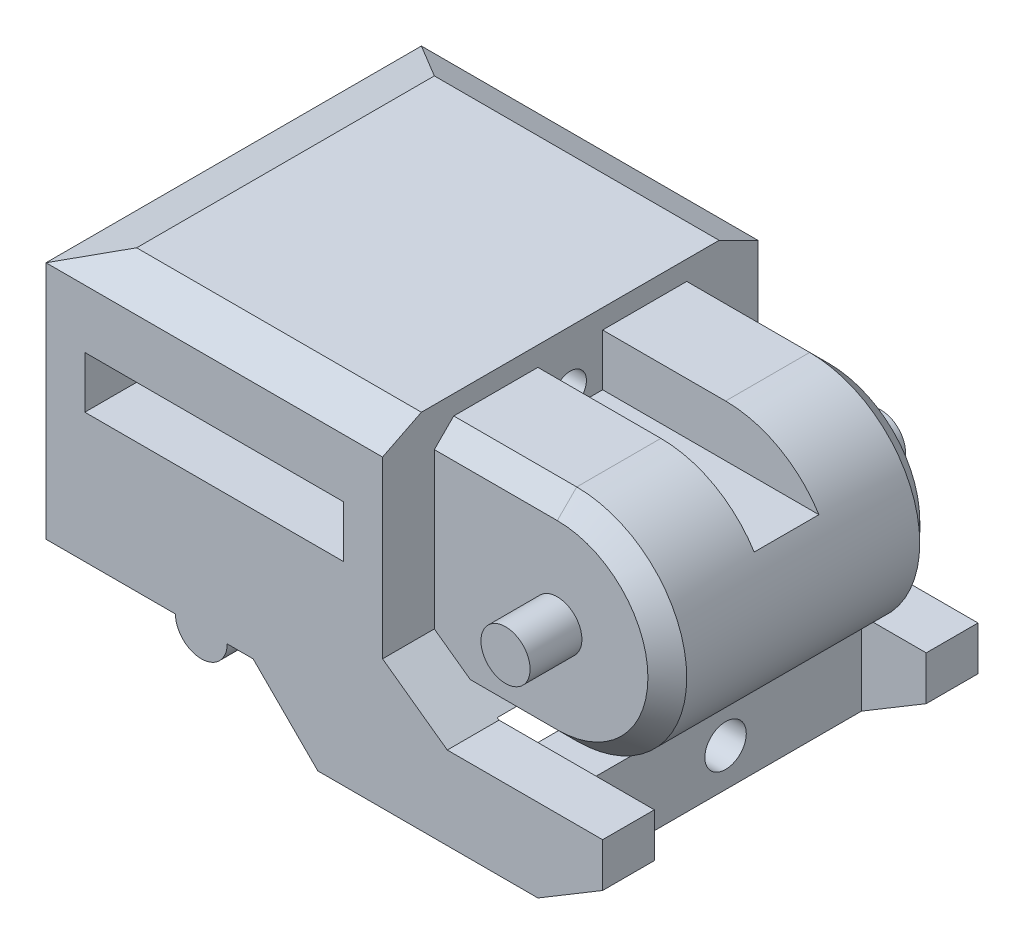
from build123d import *

# Parameters (mm, degrees)
SKETCH1_W                = 18
SKETCH1_H                = 21
BOSS_EXTRUDE1_DEPTH      = 20
CUT_EXTRUDE3_DEPTH       = 30
CUT_EXTRUDE4_DEPTH       = 27
SKETCH6_W                = 20
SKETCH6_H                = 17
CUT_EXTRUDE5_DEPTH       = 17
SKETCH9_W                = 17
SKETCH9_H                = 4
CUT_EXTRUDE7_DEPTH       = 4
SKETCH10_W               = 20
SKETCH10_H               = 4
CUT_EXTRUDE8_DEPTH       = 30
BOSS_EXTRUDE3_DEPTH      = 4
SKETCH13_W               = 18
SKETCH13_H               = 1.5
SKETCH13_W_2             = 20
CUT_EXTRUDE11_DEPTH      = 21
CUT_EXTRUDE12_DEPTH      = 26
SKETCH16_R               = 1.9
BOSS_EXTRUDE4_DEPTH      = 14.5
SKETCH22_R               = 1.25
CUT_EXTRUDE15_DEPTH      = 19
CUT_EXTRUDE15_DEPTH_BACK = 27
CHAMFER1_SIZE            = 1.5
SKETCH23_W               = 18
SKETCH23_H               = 5
CUT_EXTRUDE16_DEPTH      = 4
SKETCH24_R               = 2
BOSS_EXTRUDE7_DEPTH      = 29
BOSS_EXTRUDE8_REACH      = 31
SKETCH25_W               = 4.5
SKETCH25_H               = 5.9
SKETCH26_R               = 1.6
CUT_EXTRUDE17_DEPTH      = 10


with BuildPart() as part:
    # Sketch1 → Boss-Extrude1 (new body)
    with BuildSketch(Plane(origin=(0, 0, 0), x_dir=(1, 0, 0), z_dir=(0, 1, 0))):
        Polygon((17.5, 14.5), (-8.5, 14.5), (-8.5, -14.5), (17.5, -14.5), (17.5, -10.5), (17.5, 10.5), align=None)
        with Locations((26.5, 0)):
            Rectangle(SKETCH1_W, SKETCH1_H)
    extrude(amount=BOSS_EXTRUDE1_DEPTH)

    # Sketch3 → Cut-Extrude3 (cut, through all)
    with BuildSketch(Plane.XY.offset(14.5)):
        Polygon((-8.5, 20), (-8.5, 18.5), (-4.5, 20), align=None)
    extrude(amount=-CUT_EXTRUDE3_DEPTH, mode=Mode.SUBTRACT)

    # Sketch4 → Cut-Extrude4 (cut, through all)
    with BuildSketch(Plane(origin=(17.5, 0, 0), x_dir=(0, 0, -1), z_dir=(1, 0, 0))):
        Polygon((-14.5, 20), (-14.5, 18.5), (-11.5, 20), align=None)
        Polygon((14.5, 20), (11.5, 20), (14.5, 18.5), align=None)
    extrude(amount=-CUT_EXTRUDE4_DEPTH, mode=Mode.SUBTRACT)

    # Sketch6 → Cut-Extrude5 (cut)
    with BuildSketch(Plane.XZ):
        with Locations((4.5, 0)):
            Rectangle(SKETCH6_W, SKETCH6_H)
    extrude(amount=-CUT_EXTRUDE5_DEPTH, mode=Mode.SUBTRACT)

    # Sketch9 → Cut-Extrude7 (cut)
    with BuildSketch(Plane.ZY.offset(8.5)):
        with Locations((0, 15)):
            Rectangle(SKETCH9_W, SKETCH9_H)
    extrude(amount=-CUT_EXTRUDE7_DEPTH, mode=Mode.SUBTRACT)

    # Sketch10 → Cut-Extrude8 (cut, through all)
    with BuildSketch(Plane.XY.offset(14.5)):
        with Locations((4.5, 12)):
            Rectangle(SKETCH10_W, SKETCH10_H)
    extrude(amount=-CUT_EXTRUDE8_DEPTH, mode=Mode.SUBTRACT)

    # Sketch12 → Boss-Extrude3 (add)
    with BuildSketch(Plane.XY.offset(14.5)):
        Polygon((22.5, 1.4), (34.5, 1.4), (34.5, 0), (34.5, -2), (29.5, -5), (12.5, -5), (7.5, 0), (17.5, 0), (17.5, 5), align=None)
    boss_extrude3 = extrude(amount=-BOSS_EXTRUDE3_DEPTH)

    # Mirror1: Boss-Extrude3 across plane
    add(boss_extrude3.mirror(Plane.XY))

    # Sketch13 → Cut-Extrude11 (cut)
    with BuildSketch(Plane.XY.offset(10.5)):
        with Locations((26.5, 19.25)):
            Rectangle(SKETCH13_W, SKETCH13_H)
        with Locations((25.5, 0.75)):
            Rectangle(SKETCH13_W_2, SKETCH13_H)
    extrude(amount=-CUT_EXTRUDE11_DEPTH, mode=Mode.SUBTRACT)

    # Sketch14 → Cut-Extrude12 (cut, through all)
    with BuildSketch(Plane.XY.offset(10.5)):
        with BuildLine():
            ThreePointArc((35.5, 10), (33.01040764, 3.98959236), (27, 1.5))
            Line((27, 1.5), (35.5, 1.5))
            Line((35.5, 1.5), (35.5, 10))
        make_face()
        with BuildLine():
            Line((35.5, 18.5), (27, 18.5))
            ThreePointArc((27, 18.5), (33.01040764, 16.01040764), (35.5, 10))
            Line((35.5, 10), (35.5, 18.5))
        make_face()
    extrude(amount=-CUT_EXTRUDE12_DEPTH, mode=Mode.SUBTRACT)

    # Sketch16 → Boss-Extrude4 (add, symmetric)
    with BuildSketch(Plane.XY):
        with Locations((27, 10)):
            Circle(SKETCH16_R)
    extrude(amount=BOSS_EXTRUDE4_DEPTH, both=True)

    # Sketch22 → Cut-Extrude15 (cut, two sides)
    with BuildSketch(Plane(origin=(17.5, 0, 0), x_dir=(0, 0, -1), z_dir=(1, 0, 0))) as cut_extrude15_sk:
        with Locations((0, 15.75)):
            Circle(SKETCH22_R)
    extrude(amount=CUT_EXTRUDE15_DEPTH, mode=Mode.SUBTRACT)
    extrude(cut_extrude15_sk.sketch, amount=-CUT_EXTRUDE15_DEPTH_BACK, mode=Mode.SUBTRACT)

    # Chamfer1
    chamfer1_edges = [part.edges().sort_by_distance(p)[0] for p in [
        (22.25, 18.5, -10.5),
        (22.25, 18.5, 10.5),
        (24.680555556, 1.5, 10.5),
        (24.680555556, 1.5, -10.5),
        (35.5, 10, -10.5),
        (35.5, 10, 10.5),
    ]]
    chamfer(chamfer1_edges, length=CHAMFER1_SIZE)

    # Sketch23 → Cut-Extrude16 (cut)
    with BuildSketch(Plane(origin=(0, 18.5, 0), x_dir=(1, 0, 0), z_dir=(0, 1, 0))):
        with Locations((26.5, 0)):
            Rectangle(SKETCH23_W, SKETCH23_H)
    extrude(amount=-CUT_EXTRUDE16_DEPTH, mode=Mode.SUBTRACT)

    # Sketch24 → Boss-Extrude7 (add, through all)
    with BuildSketch(Plane.XY.offset(14.5)):
        with Locations((3.5, 0)):
            Circle(SKETCH24_R)
    extrude(amount=-BOSS_EXTRUDE7_DEPTH)

    # Sketch25 → Boss-Extrude8 (add, up to next)
    with BuildSketch(Plane.XY.offset(14.5), mode=Mode.PRIVATE) as boss_extrude8_sk1:
        with Locations((27.25, -2.05)):
            Rectangle(SKETCH25_W, SKETCH25_H)
    boss_extrude8_tool1 = extrude(boss_extrude8_sk1.sketch, amount=-BOSS_EXTRUDE8_REACH, mode=Mode.PRIVATE) - part.part
    add(boss_extrude8_tool1.solids().sort_by_distance((27.25, -2.05, 14.5))[0])

    # Sketch26 → Cut-Extrude17 (cut)
    with BuildSketch(Plane(origin=(29.5, 0, 0), x_dir=(0, 0, -1), z_dir=(1, 0, 0))):
        with Locations((0, -2.05)):
            Circle(SKETCH26_R)
    extrude(amount=-CUT_EXTRUDE17_DEPTH, mode=Mode.SUBTRACT)


solid = part.part
